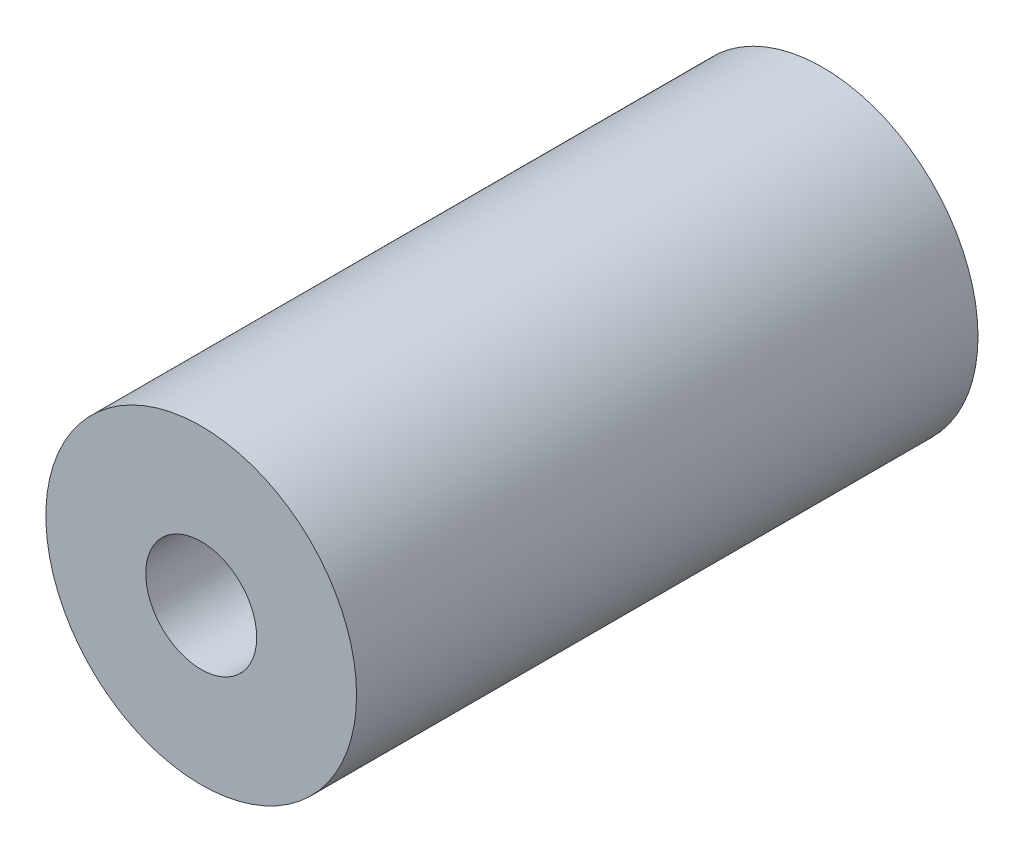
from build123d import *

# Parameters (mm, degrees)
SKETCH1_R           = 4.7625
SKETCH1_R_2         = 1.7
BOSS_EXTRUDE1_DEPTH = 9.525


with BuildPart() as part:
    # Sketch1 → Boss-Extrude1 (new body, symmetric)
    with BuildSketch(Plane.XY):
        Circle(SKETCH1_R)
        Circle(SKETCH1_R_2, mode=Mode.SUBTRACT)
    extrude(amount=BOSS_EXTRUDE1_DEPTH, both=True)


solid = part.part
